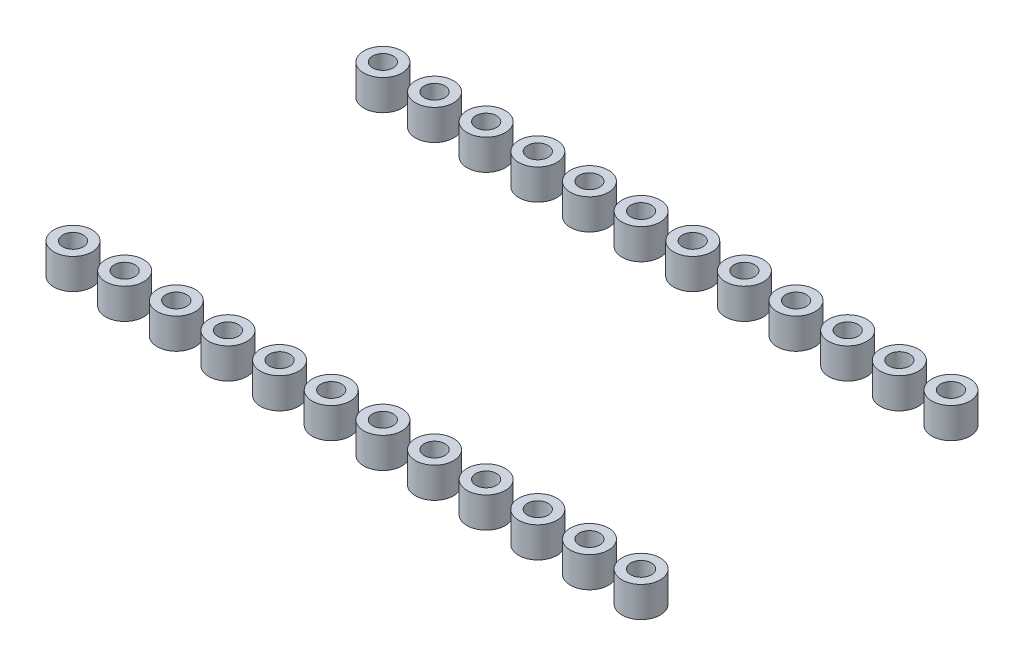
from build123d import *

# Parameters (mm, degrees)
SKETCH1_R              = 0.94
SKETCH1_R_2            = 0.508
BOSS_EXTRUDE1_DEPTH    = 1.5
BOSS_EXTRUDE1_2_DEPTH  = 1.5
BOSS_EXTRUDE1_3_DEPTH  = 1.5
BOSS_EXTRUDE1_4_DEPTH  = 1.5
BOSS_EXTRUDE1_5_DEPTH  = 1.5
BOSS_EXTRUDE1_6_DEPTH  = 1.5
BOSS_EXTRUDE1_7_DEPTH  = 1.5
BOSS_EXTRUDE1_8_DEPTH  = 1.5
BOSS_EXTRUDE1_9_DEPTH  = 1.5
BOSS_EXTRUDE1_10_DEPTH = 1.5
BOSS_EXTRUDE1_11_DEPTH = 1.5
BOSS_EXTRUDE1_12_DEPTH = 1.5
BOSS_EXTRUDE1_13_DEPTH = 1.5
BOSS_EXTRUDE1_14_DEPTH = 1.5
BOSS_EXTRUDE1_15_DEPTH = 1.5
BOSS_EXTRUDE1_16_DEPTH = 1.5
BOSS_EXTRUDE1_17_DEPTH = 1.5
BOSS_EXTRUDE1_18_DEPTH = 1.5
BOSS_EXTRUDE1_19_DEPTH = 1.5
BOSS_EXTRUDE1_20_DEPTH = 1.5
BOSS_EXTRUDE1_21_DEPTH = 1.5
BOSS_EXTRUDE1_22_DEPTH = 1.5
BOSS_EXTRUDE1_23_DEPTH = 1.5
BOSS_EXTRUDE1_24_DEPTH = 1.5


with BuildPart() as part:
    # Sketch1 → Boss-Extrude1 (new body)
    with BuildSketch(Plane(origin=(0, 0, 0), x_dir=(1, 0, 0), z_dir=(0, 1, 0))):
        with Locations((-2.815110191, 1.681457709)):
            Circle(SKETCH1_R)
        with Locations((-2.815110191, 1.681457709)):
            Circle(SKETCH1_R_2, mode=Mode.SUBTRACT)
    extrude(amount=BOSS_EXTRUDE1_DEPTH)


with BuildPart() as body_2:
    # Sketch1 → Boss-Extrude1 2 (new body)
    with BuildSketch(Plane(origin=(0, 0, 0), x_dir=(1, 0, 0), z_dir=(0, 1, 0))):
        with Locations((-0.275110191, 1.681457709)):
            Circle(SKETCH1_R)
        with Locations((-0.275110191, 1.681457709)):
            Circle(SKETCH1_R_2, mode=Mode.SUBTRACT)
    extrude(amount=BOSS_EXTRUDE1_2_DEPTH)


with BuildPart() as body_3:
    # Sketch1 → Boss-Extrude1 3 (new body)
    with BuildSketch(Plane(origin=(0, 0, 0), x_dir=(1, 0, 0), z_dir=(0, 1, 0))):
        with Locations((2.264889809, 1.681457709)):
            Circle(SKETCH1_R)
        with Locations((2.264889809, 1.681457709)):
            Circle(SKETCH1_R_2, mode=Mode.SUBTRACT)
    extrude(amount=BOSS_EXTRUDE1_3_DEPTH)


with BuildPart() as body_4:
    # Sketch1 → Boss-Extrude1 4 (new body)
    with BuildSketch(Plane(origin=(0, 0, 0), x_dir=(1, 0, 0), z_dir=(0, 1, 0))):
        with Locations((4.804889809, 1.681457709)):
            Circle(SKETCH1_R)
        with Locations((4.804889809, 1.681457709)):
            Circle(SKETCH1_R_2, mode=Mode.SUBTRACT)
    extrude(amount=BOSS_EXTRUDE1_4_DEPTH)


with BuildPart() as body_5:
    # Sketch1 → Boss-Extrude1 5 (new body)
    with BuildSketch(Plane(origin=(0, 0, 0), x_dir=(1, 0, 0), z_dir=(0, 1, 0))):
        with Locations((7.344889809, 1.681457709)):
            Circle(SKETCH1_R)
        with Locations((7.344889809, 1.681457709)):
            Circle(SKETCH1_R_2, mode=Mode.SUBTRACT)
    extrude(amount=BOSS_EXTRUDE1_5_DEPTH)


with BuildPart() as body_6:
    # Sketch1 → Boss-Extrude1 6 (new body)
    with BuildSketch(Plane(origin=(0, 0, 0), x_dir=(1, 0, 0), z_dir=(0, 1, 0))):
        with Locations((9.884889809, 1.681457709)):
            Circle(SKETCH1_R)
        with Locations((9.884889809, 1.681457709)):
            Circle(SKETCH1_R_2, mode=Mode.SUBTRACT)
    extrude(amount=BOSS_EXTRUDE1_6_DEPTH)


with BuildPart() as body_7:
    # Sketch1 → Boss-Extrude1 7 (new body)
    with BuildSketch(Plane(origin=(0, 0, 0), x_dir=(1, 0, 0), z_dir=(0, 1, 0))):
        with Locations((12.424889809, 1.681457709)):
            Circle(SKETCH1_R)
        with Locations((12.424889809, 1.681457709)):
            Circle(SKETCH1_R_2, mode=Mode.SUBTRACT)
    extrude(amount=BOSS_EXTRUDE1_7_DEPTH)


with BuildPart() as body_8:
    # Sketch1 → Boss-Extrude1 8 (new body)
    with BuildSketch(Plane(origin=(0, 0, 0), x_dir=(1, 0, 0), z_dir=(0, 1, 0))):
        with Locations((14.964889809, 1.681457709)):
            Circle(SKETCH1_R)
        with Locations((14.964889809, 1.681457709)):
            Circle(SKETCH1_R_2, mode=Mode.SUBTRACT)
    extrude(amount=BOSS_EXTRUDE1_8_DEPTH)


with BuildPart() as body_9:
    # Sketch1 → Boss-Extrude1 9 (new body)
    with BuildSketch(Plane(origin=(0, 0, 0), x_dir=(1, 0, 0), z_dir=(0, 1, 0))):
        with Locations((17.504889809, 1.681457709)):
            Circle(SKETCH1_R)
        with Locations((17.504889809, 1.681457709)):
            Circle(SKETCH1_R_2, mode=Mode.SUBTRACT)
    extrude(amount=BOSS_EXTRUDE1_9_DEPTH)


with BuildPart() as body_10:
    # Sketch1 → Boss-Extrude1 10 (new body)
    with BuildSketch(Plane(origin=(0, 0, 0), x_dir=(1, 0, 0), z_dir=(0, 1, 0))):
        with Locations((20.044889809, 1.681457709)):
            Circle(SKETCH1_R)
        with Locations((20.044889809, 1.681457709)):
            Circle(SKETCH1_R_2, mode=Mode.SUBTRACT)
    extrude(amount=BOSS_EXTRUDE1_10_DEPTH)


with BuildPart() as body_11:
    # Sketch1 → Boss-Extrude1 11 (new body)
    with BuildSketch(Plane(origin=(0, 0, 0), x_dir=(1, 0, 0), z_dir=(0, 1, 0))):
        with Locations((22.584889809, 1.681457709)):
            Circle(SKETCH1_R)
        with Locations((22.584889809, 1.681457709)):
            Circle(SKETCH1_R_2, mode=Mode.SUBTRACT)
    extrude(amount=BOSS_EXTRUDE1_11_DEPTH)


with BuildPart() as body_12:
    # Sketch1 → Boss-Extrude1 12 (new body)
    with BuildSketch(Plane(origin=(0, 0, 0), x_dir=(1, 0, 0), z_dir=(0, 1, 0))):
        with Locations((25.124889809, 1.681457709)):
            Circle(SKETCH1_R)
        with Locations((25.124889809, 1.681457709)):
            Circle(SKETCH1_R_2, mode=Mode.SUBTRACT)
    extrude(amount=BOSS_EXTRUDE1_12_DEPTH)


with BuildPart() as body_13:
    # Sketch1 → Boss-Extrude1 13 (new body)
    with BuildSketch(Plane(origin=(0, 0, 0), x_dir=(1, 0, 0), z_dir=(0, 1, 0))):
        with Locations((-0.275110191, 16.921457709)):
            Circle(SKETCH1_R)
        with Locations((-0.275110191, 16.921457709)):
            Circle(SKETCH1_R_2, mode=Mode.SUBTRACT)
    extrude(amount=BOSS_EXTRUDE1_13_DEPTH)


with BuildPart() as body_14:
    # Sketch1 → Boss-Extrude1 14 (new body)
    with BuildSketch(Plane(origin=(0, 0, 0), x_dir=(1, 0, 0), z_dir=(0, 1, 0))):
        with Locations((2.264889809, 16.921457709)):
            Circle(SKETCH1_R)
        with Locations((2.264889809, 16.921457709)):
            Circle(SKETCH1_R_2, mode=Mode.SUBTRACT)
    extrude(amount=BOSS_EXTRUDE1_14_DEPTH)


with BuildPart() as body_15:
    # Sketch1 → Boss-Extrude1 15 (new body)
    with BuildSketch(Plane(origin=(0, 0, 0), x_dir=(1, 0, 0), z_dir=(0, 1, 0))):
        with Locations((4.804889809, 16.921457709)):
            Circle(SKETCH1_R)
        with Locations((4.804889809, 16.921457709)):
            Circle(SKETCH1_R_2, mode=Mode.SUBTRACT)
    extrude(amount=BOSS_EXTRUDE1_15_DEPTH)


with BuildPart() as body_16:
    # Sketch1 → Boss-Extrude1 16 (new body)
    with BuildSketch(Plane(origin=(0, 0, 0), x_dir=(1, 0, 0), z_dir=(0, 1, 0))):
        with Locations((7.344889809, 16.921457709)):
            Circle(SKETCH1_R)
        with Locations((7.344889809, 16.921457709)):
            Circle(SKETCH1_R_2, mode=Mode.SUBTRACT)
    extrude(amount=BOSS_EXTRUDE1_16_DEPTH)


with BuildPart() as body_17:
    # Sketch1 → Boss-Extrude1 17 (new body)
    with BuildSketch(Plane(origin=(0, 0, 0), x_dir=(1, 0, 0), z_dir=(0, 1, 0))):
        with Locations((9.884889809, 16.921457709)):
            Circle(SKETCH1_R)
        with Locations((9.884889809, 16.921457709)):
            Circle(SKETCH1_R_2, mode=Mode.SUBTRACT)
    extrude(amount=BOSS_EXTRUDE1_17_DEPTH)


with BuildPart() as body_18:
    # Sketch1 → Boss-Extrude1 18 (new body)
    with BuildSketch(Plane(origin=(0, 0, 0), x_dir=(1, 0, 0), z_dir=(0, 1, 0))):
        with Locations((12.424889809, 16.921457709)):
            Circle(SKETCH1_R)
        with Locations((12.424889809, 16.921457709)):
            Circle(SKETCH1_R_2, mode=Mode.SUBTRACT)
    extrude(amount=BOSS_EXTRUDE1_18_DEPTH)


with BuildPart() as body_19:
    # Sketch1 → Boss-Extrude1 19 (new body)
    with BuildSketch(Plane(origin=(0, 0, 0), x_dir=(1, 0, 0), z_dir=(0, 1, 0))):
        with Locations((14.964889809, 16.921457709)):
            Circle(SKETCH1_R)
        with Locations((14.964889809, 16.921457709)):
            Circle(SKETCH1_R_2, mode=Mode.SUBTRACT)
    extrude(amount=BOSS_EXTRUDE1_19_DEPTH)


with BuildPart() as body_20:
    # Sketch1 → Boss-Extrude1 20 (new body)
    with BuildSketch(Plane(origin=(0, 0, 0), x_dir=(1, 0, 0), z_dir=(0, 1, 0))):
        with Locations((17.504889809, 16.921457709)):
            Circle(SKETCH1_R)
        with Locations((17.504889809, 16.921457709)):
            Circle(SKETCH1_R_2, mode=Mode.SUBTRACT)
    extrude(amount=BOSS_EXTRUDE1_20_DEPTH)


with BuildPart() as body_21:
    # Sketch1 → Boss-Extrude1 21 (new body)
    with BuildSketch(Plane(origin=(0, 0, 0), x_dir=(1, 0, 0), z_dir=(0, 1, 0))):
        with Locations((20.044889809, 16.921457709)):
            Circle(SKETCH1_R)
        with Locations((20.044889809, 16.921457709)):
            Circle(SKETCH1_R_2, mode=Mode.SUBTRACT)
    extrude(amount=BOSS_EXTRUDE1_21_DEPTH)


with BuildPart() as body_22:
    # Sketch1 → Boss-Extrude1 22 (new body)
    with BuildSketch(Plane(origin=(0, 0, 0), x_dir=(1, 0, 0), z_dir=(0, 1, 0))):
        with Locations((22.584889809, 16.921457709)):
            Circle(SKETCH1_R)
        with Locations((22.584889809, 16.921457709)):
            Circle(SKETCH1_R_2, mode=Mode.SUBTRACT)
    extrude(amount=BOSS_EXTRUDE1_22_DEPTH)


with BuildPart() as body_23:
    # Sketch1 → Boss-Extrude1 23 (new body)
    with BuildSketch(Plane(origin=(0, 0, 0), x_dir=(1, 0, 0), z_dir=(0, 1, 0))):
        with Locations((25.124889809, 16.921457709)):
            Circle(SKETCH1_R)
        with Locations((25.124889809, 16.921457709)):
            Circle(SKETCH1_R_2, mode=Mode.SUBTRACT)
    extrude(amount=BOSS_EXTRUDE1_23_DEPTH)


with BuildPart() as body_24:
    # Sketch1 → Boss-Extrude1 24 (new body)
    with BuildSketch(Plane(origin=(0, 0, 0), x_dir=(1, 0, 0), z_dir=(0, 1, 0))):
        with Locations((-2.815110191, 16.921457709)):
            Circle(SKETCH1_R)
        with Locations((-2.815110191, 16.921457709)):
            Circle(SKETCH1_R_2, mode=Mode.SUBTRACT)
    extrude(amount=BOSS_EXTRUDE1_24_DEPTH)


solid = Compound([part.part, body_2.part, body_3.part, body_4.part, body_5.part, body_6.part, body_7.part, body_8.part, body_9.part, body_10.part, body_11.part, body_12.part, body_13.part, body_14.part, body_15.part, body_16.part, body_17.part, body_18.part, body_19.part, body_20.part, body_21.part, body_22.part, body_23.part, body_24.part])
